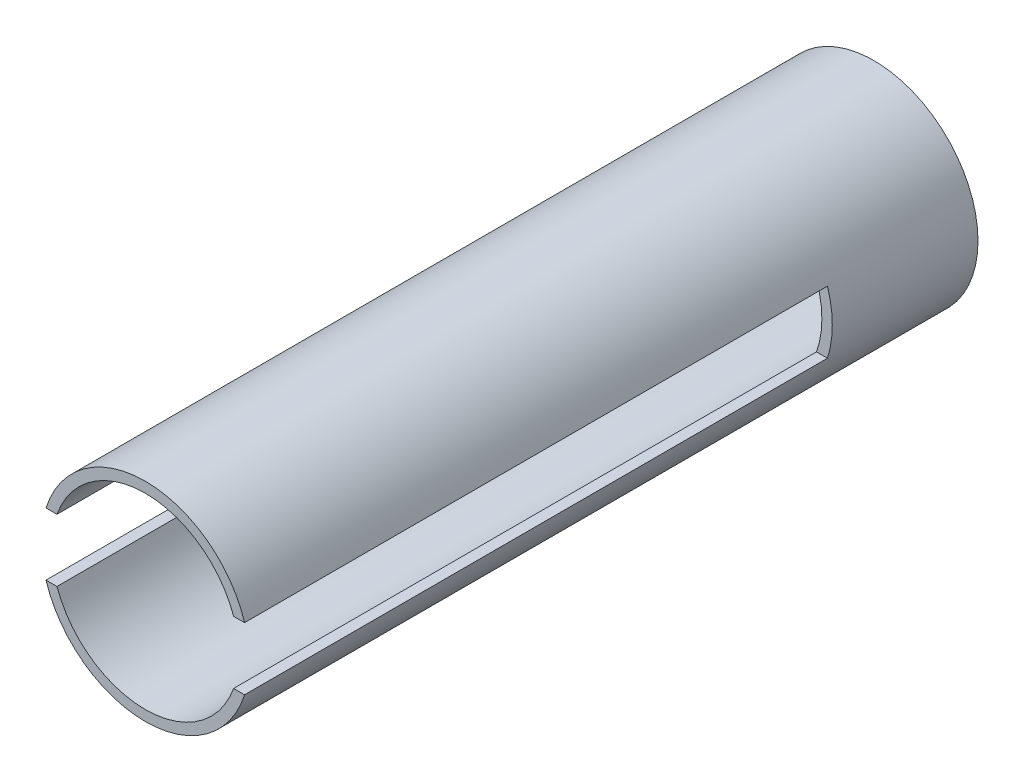
from build123d import *

# Parameters (mm, degrees)
BOSS_EXTRUDE1_DEPTH   = 177.8
BOSS_EXTRUDE1_2_DEPTH = 177.8
SKETCH2_R             = 63.5
SKETCH2_R_2           = 57.15
BOSS_EXTRUDE2_DEPTH   = 88.9


with BuildPart() as part:
    # Sketch1 → Boss-Extrude1 (new body, symmetric)
    with BuildSketch(Plane.XY):
        with BuildLine():
            ThreePointArc((60.575139, 19.05), (0, 63.5), (-60.575139, 19.05))
            Line((-60.575139, 19.05), (-53.881537, 19.05))
            ThreePointArc((-53.881537, 19.05), (0, 57.15), (53.881537, 19.05))
            Line((53.881537, 19.05), (60.575139, 19.05))
        make_face()
    extrude(amount=BOSS_EXTRUDE1_DEPTH, both=True)



with BuildPart() as body_2:
    # Sketch1 → Boss-Extrude1 2 (new body, symmetric)
    with BuildSketch(Plane.XY):
        with BuildLine():
            Line((-53.881537, -19.05), (-60.575139, -19.05))
            ThreePointArc((-60.575139, -19.05), (0, -63.5), (60.575139, -19.05))
            Line((60.575139, -19.05), (53.881537, -19.05))
            ThreePointArc((53.881537, -19.05), (0, -57.15), (-53.881537, -19.05))
        make_face()
    extrude(amount=BOSS_EXTRUDE1_2_DEPTH, both=True)


with BuildPart() as part_1:
    add(part.part)

    add(body_2.part)  # Boss-Extrude2 merges body 2
    # Sketch2 → Boss-Extrude2 (add)
    with BuildSketch(Plane(origin=(0, 0, -177.8), x_dir=(-1, 0, 0), z_dir=(0, 0, -1))):
        Circle(SKETCH2_R)
        Circle(SKETCH2_R_2, mode=Mode.SUBTRACT)
    extrude(amount=BOSS_EXTRUDE2_DEPTH)


solid = part_1.part
